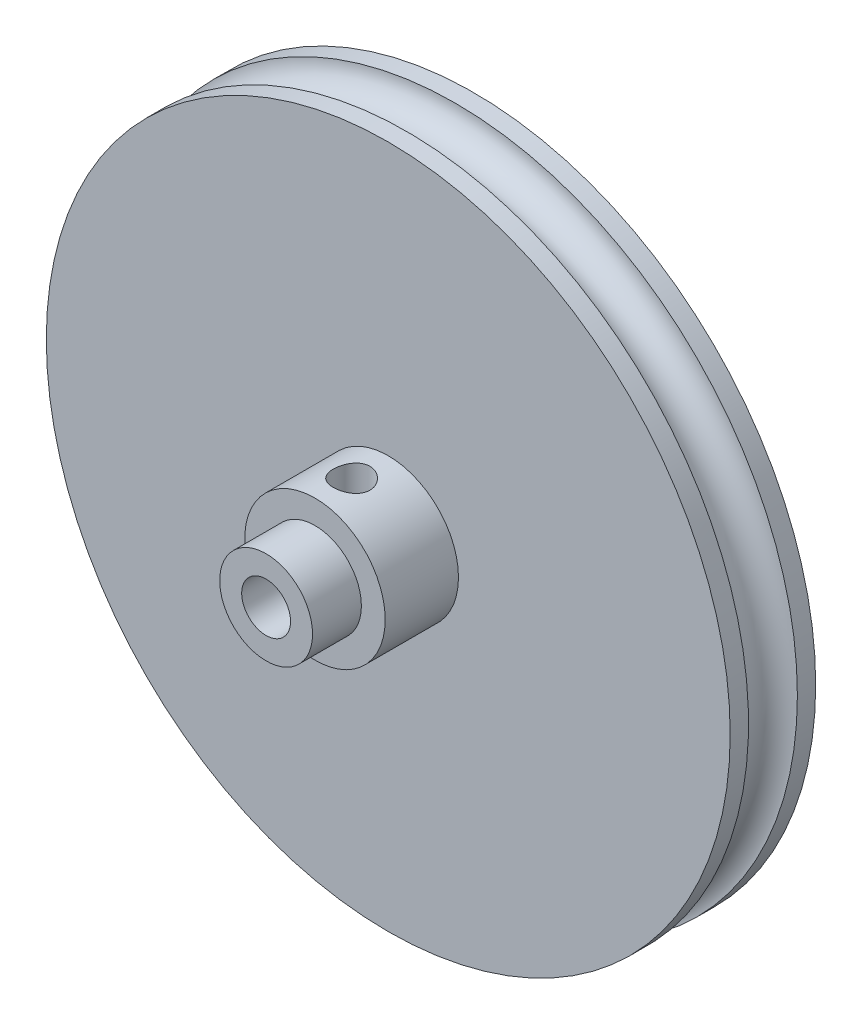
from build123d import *

# Parameters (mm, degrees)
ESQUISSE1_R             = 28
BOSS_EXTRU_1_DEPTH      = 7
ESQUISSE2_R             = 3.8
BOSS_EXTRU_2_DEPTH      = 10
ESQUISSE3_R             = 2
ENL_V_MAT_EXTRU_1_DEPTH = 18
ESQUISSE4_R             = 2
ESQUISSE5_R             = 5.75
ESQUISSE5_R_2           = 3.8
BOSS_EXTRU_3_DEPTH      = 6
ENL_V_MAT_EXTRU_2_REACH = 30
ESQUISSE6_R             = 1.5


with BuildPart() as part:
    # Esquisse1 → Boss.-Extru.1 (new body)
    with BuildSketch(Plane.XY):
        Circle(ESQUISSE1_R)
    extrude(amount=BOSS_EXTRU_1_DEPTH)

    # Esquisse2 → Boss.-Extru.2 (add)
    with BuildSketch(Plane.XY.offset(7)):
        Circle(ESQUISSE2_R)
    extrude(amount=BOSS_EXTRU_2_DEPTH)

    # Esquisse3 → Enlèv. mat.-Extru.1 (cut, through all)
    with BuildSketch(Plane.XY.offset(17)):
        Circle(ESQUISSE3_R)
    extrude(amount=-ENL_V_MAT_EXTRU_1_DEPTH, mode=Mode.SUBTRACT)

    # Esquisse4 → Enlèvement de matière-Révolution1 (revolve, cut)
    with BuildSketch(Plane(origin=(0, 0, 0), x_dir=(0, 0, -1), z_dir=(1, 0, 0))):
        with Locations((-3.5, 28)):
            Circle(ESQUISSE4_R)
    revolve(axis=Axis((0, 0, 0), (0, 0, 1)), mode=Mode.SUBTRACT)

    # Esquisse5 → Boss.-Extru.3 (add)
    with BuildSketch(Plane.XY.offset(7)):
        Circle(ESQUISSE5_R)
        Circle(ESQUISSE5_R_2, mode=Mode.SUBTRACT)
    extrude(amount=BOSS_EXTRU_3_DEPTH)

    # Esquisse6 → Enlèv. mat.-Extru.2 (cut, up to next)
    with BuildSketch(Plane(origin=(0, 0, 0), x_dir=(1, 0, 0), z_dir=(0, 1, 0)), mode=Mode.PRIVATE) as enl_v_mat_extru_2_sk1:
        with Locations((0, -10)):
            Circle(ESQUISSE6_R)
    enl_v_mat_extru_2_tool1 = extrude(enl_v_mat_extru_2_sk1.sketch, amount=ENL_V_MAT_EXTRU_2_REACH, mode=Mode.PRIVATE) & part.part
    add(enl_v_mat_extru_2_tool1.solids().sort_by_distance((0, 0, 10))[0], mode=Mode.SUBTRACT)


solid = part.part
